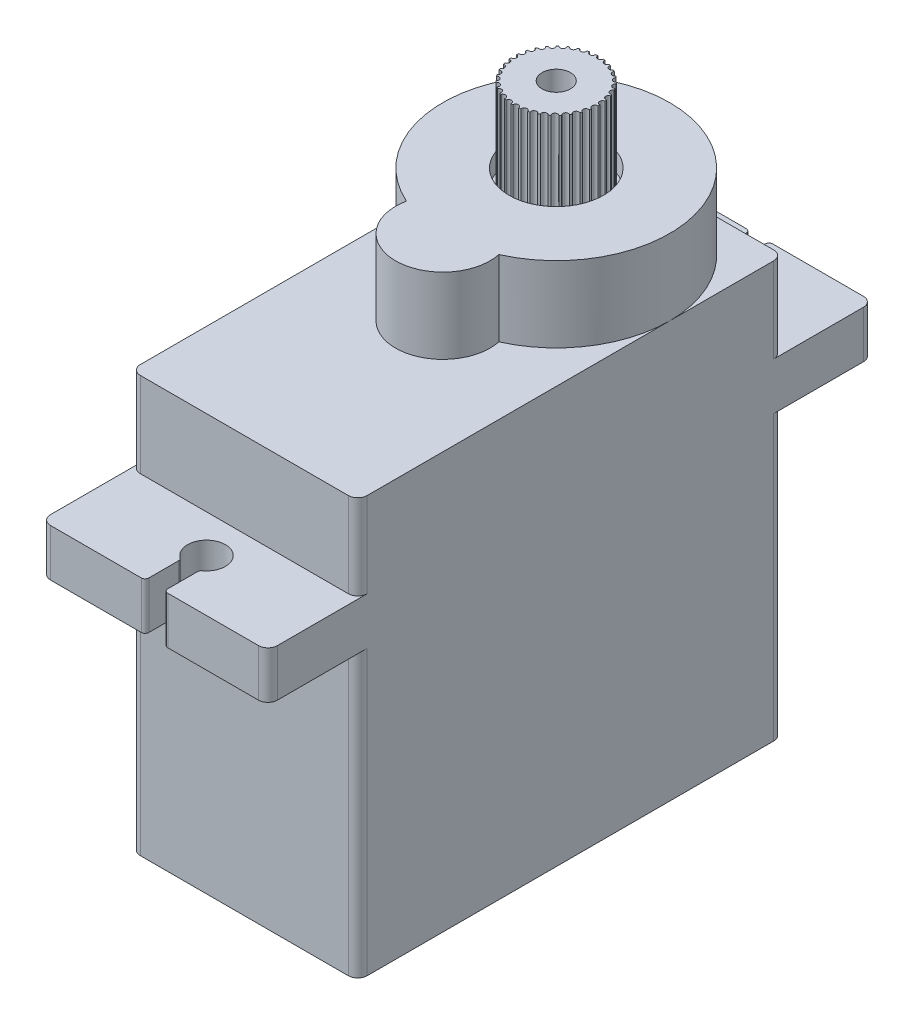
from build123d import *

# Parameters (mm, degrees)
Y_KSEKLIK_EKSTR_ZYON1_DEPTH  = 1
Y_KSEKLIK_EKSTR_ZYON2_DEPTH  = 5
IZIM3_W                      = 4
IZIM3_H                      = 1
KES_EKSTR_ZYON1_DEPTH        = 1
RADYUS1_R                    = 0.1
Y_KSEKLIK_EKSTR_ZYON4_DEPTH  = 9
Y_KSEKLIK_EKSTR_ZYON5_DEPTH  = 2.5
Y_KSEKLIK_EKSTR_ZYON6_DEPTH  = 3.5
Y_KSEKLIK_EKSTR_ZYON7_DEPTH  = 1
KES_EKSTR_ZYON2_DEPTH        = 1
Y_KSEKLIK_EKSTR_ZYON8_DEPTH  = 3
RADYUS2_R                    = 0.5
Y_KSEKLIK_EKSTR_ZYON9_DEPTH  = 1
IZIM11_R                     = 2.5
KES_EKSTR_ZYON3_DEPTH        = 10
IZIM15_R                     = 0.25
Y_KSEKLIK_EKSTR_ZYON12_DEPTH = 11
IZIM19_R                     = 2.25
Y_KSEKLIK_EKSTR_ZYON17_DEPTH = 5
IZIM20_R                     = 4.75
Y_KSEKLIK_EKSTR_ZYON18_DEPTH = 3
IZIM21_R                     = 0.75
KES_EKSTR_ZYON5_DEPTH        = 10
IZIM22_R                     = 0.5
Y_KSEKLIK_EKSTR_ZYON19_DEPTH = 5
IZIM23_R                     = 4
Y_KSEKLIK_EKSTR_ZYON20_DEPTH = 2
IZIM24_R                     = 0.75
Y_KSEKLIK_EKSTR_ZYON21_DEPTH = 7
IZIM25_R                     = 3.5
Y_KSEKLIK_EKSTR_ZYON22_DEPTH = 1
IZIM26_R                     = 4.5
Y_KSEKLIK_EKSTR_ZYON23_DEPTH = 1
KES_EKSTR_ZYON7_DEPTH        = 30
Y_KSEKLIK_EKSTR_ZYON33_DEPTH = 1
Y_KSEKLIK_EKSTR_ZYON34_DEPTH = 14
IZIM37_W                     = 8
IZIM37_H                     = 6
Y_KSEKLIK_EKSTR_ZYON36_DEPTH = 1
IZIM39_W                     = 4
IZIM39_H                     = 1
Y_KSEKLIK_EKSTR_ZYON37_DEPTH = 0.1
IZIM40_R                     = 0.4
Y_KSEKLIK_EKSTR_ZYON38_DEPTH = 2
IZIM41_R                     = 0.15
KES_EKSTR_ZYON8_DEPTH        = 5


with BuildPart() as part:
    # izim1 → Y_kseklik-Ekstr_zyon1 (new body)
    with BuildSketch(Plane(origin=(0, 0, 0), x_dir=(1, 0, 0), z_dir=(0, 1, 0))):
        with BuildLine():
            Line((-5.5, 11.25), (5.5, 11.25))
            ThreePointArc((5.5, 11.25), (5.853553391, 11.103553391), (6, 10.75))
            Line((6, 10.75), (6, -10.75))
            ThreePointArc((6, -10.75), (5.853553391, -11.103553391), (5.5, -11.25))
            Line((5.5, -11.25), (-5.5, -11.25))
            ThreePointArc((-5.5, -11.25), (-5.853553391, -11.103553391), (-6, -10.75))
            Line((-6, -10.75), (-6, 10.75))
            ThreePointArc((-6, 10.75), (-5.853553391, 11.103553391), (-5.5, 11.25))
        make_face()
    extrude(amount=Y_KSEKLIK_EKSTR_ZYON1_DEPTH)

    # izim2 → Y_kseklik-Ekstr_zyon2 (add)
    with BuildSketch(Plane(origin=(0, 1, 0), x_dir=(1, 0, 0), z_dir=(0, 1, 0))):
        with BuildLine():
            Line((-5.5, 11.25), (5.5, 11.25))
            ThreePointArc((5.5, 11.25), (5.853553391, 11.103553391), (6, 10.75))
            Line((6, 10.75), (6, -10.75))
            ThreePointArc((6, -10.75), (5.853553391, -11.103553391), (5.5, -11.25))
            Line((5.5, -11.25), (-5.5, -11.25))
            ThreePointArc((-5.5, -11.25), (-5.853553391, -11.103553391), (-6, -10.75))
            Line((-6, -10.75), (-6, 10.75))
            ThreePointArc((-6, 10.75), (-5.853553391, 11.103553391), (-5.5, 11.25))
        make_face()
        with BuildLine():
            Line((-5, 9.25), (-5, -9.25))
            ThreePointArc((-5, -9.25), (-4.292893219, -9.542893219), (-4, -10.25))
            Line((-4, -10.25), (4, -10.25))
            ThreePointArc((4, -10.25), (4.292893219, -9.542893219), (5, -9.25))
            Line((5, -9.25), (5, 9.25))
            ThreePointArc((5, 9.25), (4.292893219, 9.542893219), (4, 10.25))
            Line((4, 10.25), (-4, 10.25))
            ThreePointArc((-4, 10.25), (-4.292893219, 9.542893219), (-5, 9.25))
        make_face(mode=Mode.SUBTRACT)
    extrude(amount=Y_KSEKLIK_EKSTR_ZYON2_DEPTH)

    # izim3 → Kes-Ekstr_zyon1 (cut)
    with BuildSketch(Plane(origin=(0, 6, 0), x_dir=(1, 0, 0), z_dir=(0, 1, 0))):
        with Locations((0, -10.75)):
            Rectangle(IZIM3_W, IZIM3_H)
    extrude(amount=-KES_EKSTR_ZYON1_DEPTH, mode=Mode.SUBTRACT)

    # Radyus1
    radyus1_edges = [part.edges().sort_by_distance(p)[0] for p in [
        (2, 5, 10.75),
        (-2, 5, 10.75),
    ]]
    fillet(radyus1_edges, radius=RADYUS1_R)

    # izim4 → Y_kseklik-Ekstr_zyon4 (add)
    with BuildSketch(Plane(origin=(0, 6, 0), x_dir=(1, 0, 0), z_dir=(0, 1, 0))):
        with BuildLine():
            Line((-5.5, 11.25), (5.5, 11.25))
            ThreePointArc((5.5, 11.25), (5.853553391, 11.103553391), (6, 10.75))
            Line((6, 10.75), (6, -10.75))
            ThreePointArc((6, -10.75), (5.853553391, -11.103553391), (5.5, -11.25))
            Line((5.5, -11.25), (-5.5, -11.25))
            ThreePointArc((-5.5, -11.25), (-5.853553391, -11.103553391), (-6, -10.75))
            Line((-6, -10.75), (-6, 10.75))
            ThreePointArc((-6, 10.75), (-5.853553391, 11.103553391), (-5.5, 11.25))
        make_face()
        with BuildLine():
            Line((-4, 10.25), (4, 10.25))
            ThreePointArc((4, 10.25), (4.292893219, 9.542893219), (5, 9.25))
            Line((5, 9.25), (5, -9.25))
            ThreePointArc((5, -9.25), (4.292893219, -9.542893219), (4, -10.25))
            Line((4, -10.25), (-4, -10.25))
            ThreePointArc((-4, -10.25), (-4.292893219, -9.542893219), (-5, -9.25))
            Line((-5, -9.25), (-5, 9.25))
            ThreePointArc((-5, 9.25), (-4.292893219, 9.542893219), (-4, 10.25))
        make_face(mode=Mode.SUBTRACT)
    extrude(amount=Y_KSEKLIK_EKSTR_ZYON4_DEPTH)

    # izim6 → Y_kseklik-Ekstr_zyon5 (add)
    with BuildSketch(Plane(origin=(0, 15, 0), x_dir=(1, 0, 0), z_dir=(0, 1, 0))):
        with BuildLine():
            Line((-5.5, 16), (-0.7, 16))
            ThreePointArc((-0.7, 16), (-0.558578644, 15.941421356), (-0.5, 15.8))
            Line((-0.5, 15.8), (-0.5, 14.224679434))
            ThreePointArc((-0.5, 14.224679434), (-0.522048696, 14.133392342), (-0.583333333, 14.062232862))
            ThreePointArc((-0.583333333, 14.062232862), (0, 12.25), (0.583333333, 14.062232862))
            ThreePointArc((0.583333333, 14.062232862), (0.522048696, 14.133392342), (0.5, 14.224679434))
            Line((0.5, 14.224679434), (0.5, 15.8))
            ThreePointArc((0.5, 15.8), (0.558578644, 15.941421356), (0.7, 16))
            Line((0.7, 16), (5.5, 16))
            ThreePointArc((5.5, 16), (5.853553391, 15.853553391), (6, 15.5))
            Line((6, 15.5), (6, -15.5))
            ThreePointArc((6, -15.5), (5.853553391, -15.853553391), (5.5, -16))
            Line((5.5, -16), (0.7, -16))
            ThreePointArc((0.7, -16), (0.558578644, -15.941421356), (0.5, -15.8))
            Line((0.5, -15.8), (0.5, -14.224679434))
            ThreePointArc((0.5, -14.224679434), (0.522048696, -14.133392342), (0.583333333, -14.062232862))
            ThreePointArc((0.583333333, -14.062232862), (0, -12.25), (-0.583333333, -14.062232862))
            ThreePointArc((-0.583333333, -14.062232862), (-0.522048696, -14.133392342), (-0.5, -14.224679434))
            Line((-0.5, -14.224679434), (-0.5, -15.8))
            ThreePointArc((-0.5, -15.8), (-0.558578644, -15.941421356), (-0.7, -16))
            Line((-0.7, -16), (-5.5, -16))
            ThreePointArc((-5.5, -16), (-5.853553391, -15.853553391), (-6, -15.5))
            Line((-6, -15.5), (-6, 15.5))
            ThreePointArc((-6, 15.5), (-5.853553391, 15.853553391), (-5.5, 16))
        make_face()
        with BuildLine():
            Line((-4, 10.25), (4, 10.25))
            ThreePointArc((4, 10.25), (4.292893219, 9.542893219), (5, 9.25))
            Line((5, 9.25), (5, -9.25))
            ThreePointArc((5, -9.25), (4.292893219, -9.542893219), (4, -10.25))
            Line((4, -10.25), (-4, -10.25))
            ThreePointArc((-4, -10.25), (-4.292893219, -9.542893219), (-5, -9.25))
            Line((-5, -9.25), (-5, 9.25))
            ThreePointArc((-5, 9.25), (-4.292893219, 9.542893219), (-4, 10.25))
        make_face(mode=Mode.SUBTRACT)
    extrude(amount=Y_KSEKLIK_EKSTR_ZYON5_DEPTH)

    # izim7 → Y_kseklik-Ekstr_zyon6 (add)
    with BuildSketch(Plane(origin=(0, 17.5, 0), x_dir=(1, 0, 0), z_dir=(0, 1, 0))):
        with BuildLine():
            Line((5.5, 11.25), (-5.5, 11.25))
            ThreePointArc((-5.5, 11.25), (-5.853553391, 11.103553391), (-6, 10.75))
            Line((-6, 10.75), (-6, -10.75))
            ThreePointArc((-6, -10.75), (-5.853553391, -11.103553391), (-5.5, -11.25))
            Line((-5.5, -11.25), (5.5, -11.25))
            ThreePointArc((5.5, -11.25), (5.853553391, -11.103553391), (6, -10.75))
            Line((6, -10.75), (6, 10.75))
            ThreePointArc((6, 10.75), (5.853553391, 11.103553391), (5.5, 11.25))
        make_face()
        with BuildLine():
            Line((-5, -9.25), (-5, 9.25))
            ThreePointArc((-5, 9.25), (-4.292893219, 9.542893219), (-4, 10.25))
            Line((-4, 10.25), (4, 10.25))
            ThreePointArc((4, 10.25), (4.292893219, 9.542893219), (5, 9.25))
            Line((5, 9.25), (5, -9.25))
            ThreePointArc((5, -9.25), (4.292893219, -9.542893219), (4, -10.25))
            Line((4, -10.25), (-4, -10.25))
            ThreePointArc((-4, -10.25), (-4.292893219, -9.542893219), (-5, -9.25))
        make_face(mode=Mode.SUBTRACT)
    extrude(amount=Y_KSEKLIK_EKSTR_ZYON6_DEPTH)

    # izim8 → Y_kseklik-Ekstr_zyon7 (add)
    with BuildSketch(Plane(origin=(0, 21, 0), x_dir=(1, 0, 0), z_dir=(0, 1, 0))):
        with BuildLine():
            Line((-5.5, 11.25), (5.5, 11.25))
            ThreePointArc((5.5, 11.25), (5.853553391, 11.103553391), (6, 10.75))
            Line((6, 10.75), (6, -10.75))
            ThreePointArc((6, -10.75), (5.853553391, -11.103553391), (5.5, -11.25))
            Line((5.5, -11.25), (-5.5, -11.25))
            ThreePointArc((-5.5, -11.25), (-5.853553391, -11.103553391), (-6, -10.75))
            Line((-6, -10.75), (-6, 10.75))
            ThreePointArc((-6, 10.75), (-5.853553391, 11.103553391), (-5.5, 11.25))
        make_face()
    extrude(amount=Y_KSEKLIK_EKSTR_ZYON7_DEPTH)

    # izim9 → Kes-Ekstr_zyon2 (cut)
    with BuildSketch(Plane(origin=(0, 22, 0), x_dir=(1, 0, 0), z_dir=(0, 1, 0))):
        with BuildLine():
            ThreePointArc((1.015291078, 0.354166667), (0, 10.25), (-1.015291078, 0.354166667))
            ThreePointArc((-1.015291078, 0.354166667), (0, -2.25), (1.015291078, 0.354166667))
        make_face()
    extrude(amount=-KES_EKSTR_ZYON2_DEPTH, mode=Mode.SUBTRACT)

    # izim9_3 → Y_kseklik-Ekstr_zyon8 (add)
    with BuildSketch(Plane(origin=(0, 22, 0), x_dir=(1, 0, 0), z_dir=(0, 1, 0))):
        with BuildLine():
            ThreePointArc((2.445144707, -0.229166667), (0, 11.25), (-2.445144707, -0.229166667))
            ThreePointArc((-2.445144707, -0.229166667), (0, -3.25), (2.445144707, -0.229166667))
        make_face()
        with BuildLine():
            ThreePointArc((1.015291078, 0.354166667), (0, 10.25), (-1.015291078, 0.354166667))
            ThreePointArc((-1.015291078, 0.354166667), (0, -2.25), (1.015291078, 0.354166667))
        make_face(mode=Mode.SUBTRACT)
    extrude(amount=Y_KSEKLIK_EKSTR_ZYON8_DEPTH)

    # Radyus2
    radyus2_edges = [part.edges().sort_by_distance(p)[0] for p in [
        (-1.015291078, 23, -0.354166667),
        (1.015291078, 23, -0.354166667),
    ]]
    fillet(radyus2_edges, radius=RADYUS2_R)

    # izim10 → Y_kseklik-Ekstr_zyon9 (add)
    with BuildSketch(Plane(origin=(0, 25, 0), x_dir=(1, 0, 0), z_dir=(0, 1, 0))):
        with BuildLine():
            ThreePointArc((2.445144707, -0.229166667), (0, 11.25), (-2.445144707, -0.229166667))
            ThreePointArc((-2.445144707, -0.229166667), (0, -3.25), (2.445144707, -0.229166667))
        make_face()
    extrude(amount=Y_KSEKLIK_EKSTR_ZYON9_DEPTH)

    # izim11 → Kes-Ekstr_zyon3 (cut)
    with BuildSketch(Plane(origin=(0, 26, 0), x_dir=(1, 0, 0), z_dir=(0, 1, 0))):
        with Locations(Location((0, 5.25, 0), (0, 0, 270))):
            Circle(IZIM11_R)
    extrude(amount=-KES_EKSTR_ZYON3_DEPTH, mode=Mode.SUBTRACT)

    # izim15 → Y_kseklik-Ekstr_zyon12 (add)
    with BuildSketch(Plane(origin=(0, 26, 0), x_dir=(1, 0, 0), z_dir=(0, 1, 0))):
        with Locations(Location((0, -0.75, 0), (0, 0, 270))):
            Circle(IZIM15_R)
    extrude(amount=-Y_KSEKLIK_EKSTR_ZYON12_DEPTH)



with BuildPart() as body_2:
    # izim19 → Y_kseklik-Ekstr_zyon17 (new body)
    with BuildSketch(Plane(origin=(0, 30, 0), x_dir=(1, 0, 0), z_dir=(0, 1, 0))):
        with Locations(Location((0, 5.25, 0), (0, 0, 270))):
            Circle(IZIM19_R)
    extrude(amount=-Y_KSEKLIK_EKSTR_ZYON17_DEPTH)


with BuildPart() as part_1:
    add(part.part)

    add(body_2.part)  # Y_kseklik-Ekstr_zyon18 merges body 2
    # izim20 → Y_kseklik-Ekstr_zyon18 (add)
    with BuildSketch(Plane.XZ.offset(-25)):
        with Locations(Location((0, -5.25, 0), (0, 0, 90))):
            Circle(IZIM20_R)
    extrude(amount=Y_KSEKLIK_EKSTR_ZYON18_DEPTH)

    # izim21 → Kes-Ekstr_zyon5 (cut)
    with BuildSketch(Plane(origin=(0, 30, 0), x_dir=(1, 0, 0), z_dir=(0, 1, 0))):
        with Locations(Location((0, 5.25, 0), (0, 0, 270))):
            Circle(IZIM21_R)
    extrude(amount=-KES_EKSTR_ZYON5_DEPTH, mode=Mode.SUBTRACT)

    # izim22 → Y_kseklik-Ekstr_zyon19 (add)
    with BuildSketch(Plane(origin=(0, 25.5, 0), x_dir=(1, 0, 0), z_dir=(0, 1, 0))):
        with Locations(Location((0, -0.75, 0), (0, 0, 270))):
            Circle(IZIM22_R)
    extrude(amount=-Y_KSEKLIK_EKSTR_ZYON19_DEPTH)

    # izim23 → Y_kseklik-Ekstr_zyon20 (add)
    with BuildSketch(Plane.XZ.offset(-20.5)):
        with Locations(Location((0, 0.75, 0), (0, 0, 270))):
            Circle(IZIM23_R)
    extrude(amount=Y_KSEKLIK_EKSTR_ZYON20_DEPTH)

    # izim26 → Y_kseklik-Ekstr_zyon23 (add)
    with BuildSketch(Plane(origin=(0, 17.5, 0), x_dir=(-1, 0, 0), z_dir=(0, -1, 0))):
        with Locations(Location((0, -0.75, 0), (0, 0, 90))):
            Circle(IZIM26_R)
    extrude(amount=Y_KSEKLIK_EKSTR_ZYON23_DEPTH)

    # izim32 → Kes-Ekstr_zyon7 (cut)
    with BuildSketch(Plane(origin=(0, 0, 10.25), x_dir=(-1, 0, 0), z_dir=(0, 0, -1))):
        with BuildLine():
            Line((2, 6), (-2, 6))
            Line((-2, 6), (-2, 5.1))
            ThreePointArc((-2, 5.1), (-1.970710678, 5.029289322), (-1.9, 5))
            Line((-1.9, 5), (1.9, 5))
            ThreePointArc((1.9, 5), (1.970710678, 5.029289322), (2, 5.1))
            Line((2, 5.1), (2, 6))
        make_face()
    extrude(amount=KES_EKSTR_ZYON7_DEPTH, mode=Mode.SUBTRACT)

    # izim33 → Y_kseklik-Ekstr_zyon33 (add)
    with BuildSketch(Plane.XY.offset(11.25)):
        with BuildLine():
            Line((-2, 6), (2, 6))
            Line((2, 6), (2, 5.1))
            ThreePointArc((2, 5.1), (1.970710678, 5.029289322), (1.9, 5))
            Line((1.9, 5), (-1.9, 5))
            ThreePointArc((-1.9, 5), (-1.970710678, 5.029289322), (-2, 5.1))
            Line((-2, 5.1), (-2, 6))
        make_face()
    extrude(amount=-Y_KSEKLIK_EKSTR_ZYON33_DEPTH)

    # izim34 → Y_kseklik-Ekstr_zyon34 (add)
    with BuildSketch(Plane(origin=(0, 1, 0), x_dir=(1, 0, 0), z_dir=(0, 1, 0))):
        with BuildLine():
            Line((-3, -3.25), (3, -3.25))
            ThreePointArc((3, -3.25), (3.707106781, -3.542893219), (4, -4.25))
            Line((4, -4.25), (4, -8.25))
            ThreePointArc((4, -8.25), (3.707106781, -8.957106781), (3, -9.25))
            Line((3, -9.25), (-3, -9.25))
            ThreePointArc((-3, -9.25), (-3.707106781, -8.957106781), (-4, -8.25))
            Line((-4, -8.25), (-4, -4.25))
            ThreePointArc((-4, -4.25), (-3.707106781, -3.542893219), (-3, -3.25))
        make_face()
    extrude(amount=Y_KSEKLIK_EKSTR_ZYON34_DEPTH)

    # izim37 → Y_kseklik-Ekstr_zyon36 (add)
    with BuildSketch(Plane(origin=(0, 1, 0), x_dir=(-1, 0, 0), z_dir=(0, -1, 0))):
        with Locations((0, -6.25)):
            Rectangle(IZIM37_W, IZIM37_H)
    extrude(amount=-Y_KSEKLIK_EKSTR_ZYON36_DEPTH)

    # izim39 → Y_kseklik-Ekstr_zyon37 (add)
    with BuildSketch(Plane(origin=(0, 0, -10.75), x_dir=(-1, 0, 0), z_dir=(0, 0, -1))):
        with Locations((0, 5.514566781)):
            Rectangle(IZIM39_W, IZIM39_H)
    extrude(amount=Y_KSEKLIK_EKSTR_ZYON37_DEPTH)

    # izim40 → Y_kseklik-Ekstr_zyon38 (add)
    with BuildSketch(Plane(origin=(0, 0, -10.85), x_dir=(-1, 0, 0), z_dir=(0, 0, -1))):
        with Locations((0, 5.55)):
            Circle(IZIM40_R)
        with Locations((1, 5.55)):
            Circle(IZIM40_R)
        with Locations((-1, 5.55)):
            Circle(IZIM40_R)
    extrude(amount=Y_KSEKLIK_EKSTR_ZYON38_DEPTH)

    # izim41 → Kes-Ekstr_zyon8 (cut)
    with BuildSketch(Plane(origin=(0, 30, 0), x_dir=(1, 0, 0), z_dir=(0, 1, 0))):
        with Locations((-2.25, 5.25)):
            Circle(IZIM41_R)
        with Locations((-2.213841574, 5.651753013)):
            Circle(IZIM41_R)
        with Locations((-2.106528459, 6.040593354)):
            Circle(IZIM41_R)
        with Locations((-1.931509786, 6.404023374)):
            Circle(IZIM41_R)
        with Locations((-1.694410799, 6.730362133)):
            Circle(IZIM41_R)
        with Locations((-1.402852054, 7.009120836)):
            Circle(IZIM41_R)
        with Locations((-1.066204491, 7.231339947)):
            Circle(IZIM41_R)
        with Locations((-0.695288237, 7.389877162)):
            Circle(IZIM41_R)
        with Locations((-0.302024848, 7.479636964)):
            Circle(IZIM41_R)
        with Locations((0.100945868, 7.4977344)):
            Circle(IZIM41_R)
        with Locations((0.500672101, 7.443587802)):
            Circle(IZIM41_R)
        with Locations((0.884306321, 7.318937488)):
            Circle(IZIM41_R)
        with Locations((1.239518208, 7.127789821)):
            Circle(IZIM41_R)
        with Locations((1.55489096, 6.876288444)):
            Circle(IZIM41_R)
        with Locations((1.820288237, 6.572516818)):
            Circle(IZIM41_R)
        with Locations((2.027179953, 6.226238413)):
            Circle(IZIM41_R)
        with Locations((2.168916437, 5.848582903)):
            Circle(IZIM41_R)
        with Locations((2.240942161, 5.451688445)):
            Circle(IZIM41_R)
        with Locations((2.240942161, 5.048311555)):
            Circle(IZIM41_R)
        with Locations((2.168916437, 4.651417097)):
            Circle(IZIM41_R)
        with Locations((2.027179953, 4.273761587)):
            Circle(IZIM41_R)
        with Locations((1.820288237, 3.927483182)):
            Circle(IZIM41_R)
        with Locations((1.55489096, 3.623711556)):
            Circle(IZIM41_R)
        with Locations((1.239518208, 3.372210179)):
            Circle(IZIM41_R)
        with Locations((0.884306321, 3.181062512)):
            Circle(IZIM41_R)
        with Locations((0.500672101, 3.056412198)):
            Circle(IZIM41_R)
        with Locations((0.100945868, 3.0022656)):
            Circle(IZIM41_R)
        with Locations((-0.302024848, 3.020363036)):
            Circle(IZIM41_R)
        with Locations((-0.695288237, 3.110122838)):
            Circle(IZIM41_R)
        with Locations((-1.066204491, 3.268660053)):
            Circle(IZIM41_R)
        with Locations((-1.402852054, 3.490879164)):
            Circle(IZIM41_R)
        with Locations((-1.694410799, 3.769637867)):
            Circle(IZIM41_R)
        with Locations((-1.931509786, 4.095976626)):
            Circle(IZIM41_R)
        with Locations((-2.106528459, 4.459406646)):
            Circle(IZIM41_R)
        with Locations((-2.213841574, 4.848246987)):
            Circle(IZIM41_R)
    extrude(amount=-KES_EKSTR_ZYON8_DEPTH, mode=Mode.SUBTRACT)


with BuildPart() as body_2_2:
    # izim24 → Y_kseklik-Ekstr_zyon21 (new body)
    with BuildSketch(Plane.XZ.offset(-22)):
        with Locations(Location((0, -5.25, 0), (0, 0, 270))):
            Circle(IZIM24_R)
    extrude(amount=Y_KSEKLIK_EKSTR_ZYON21_DEPTH)

    # izim25 → Y_kseklik-Ekstr_zyon22 (add)
    with BuildSketch(Plane(origin=(0, 19, 0), x_dir=(-1, 0, 0), z_dir=(0, -1, 0))):
        with Locations(Location((0, 5.25, 0), (0, 0, 90))):
            Circle(IZIM25_R)
    extrude(amount=Y_KSEKLIK_EKSTR_ZYON22_DEPTH)


solid = Compound([part_1.part, body_2_2.part])
